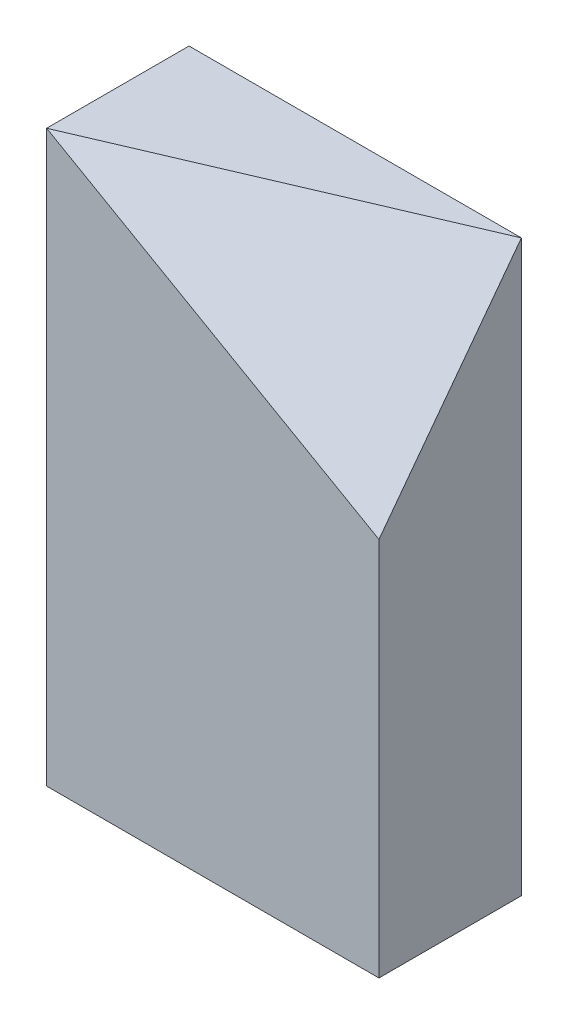
from build123d import *

# Parameters (mm, degrees)
SKETCH1_W           = 88.9
SKETCH1_H           = 152.4
BOSS_EXTRUDE1_DEPTH = 38.1


with BuildPart() as part:
    # Sketch1 → Boss-Extrude1 (new body)
    with BuildSketch(Plane.XY):
        with Locations((44.45, 76.2)):
            Rectangle(SKETCH1_W, SKETCH1_H)
    extrude(amount=BOSS_EXTRUDE1_DEPTH)

    # SurfaceCut1
    split(bisect_by=Plane(origin=(37.404236669, 65.457414171, 87.276552228), x_dir=(0.9459459459459459, -0.19459459459459455, -0.2594594594594596), z_dir=(0.3243243243243244, 0.5675675675675675, 0.7567567567567568)), keep=Keep.BOTTOM)


solid = part.part
